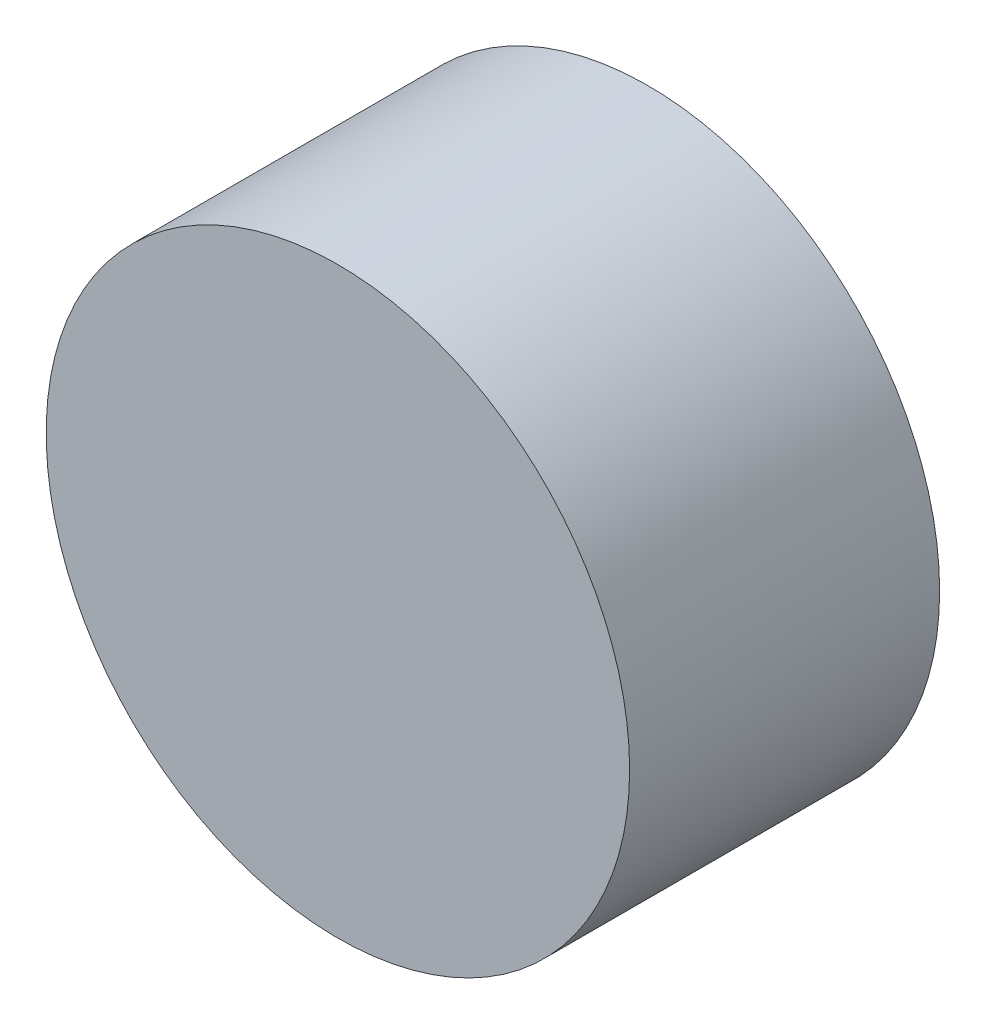
from build123d import *

# Parameters (mm, degrees)
SKETCH1_R           = 9.41
BOSS_EXTRUDE1_DEPTH = 10


with BuildPart() as part:
    # Sketch1 → Boss-Extrude1 (new body)
    with BuildSketch(Plane.XY):
        Circle(SKETCH1_R)
    extrude(amount=BOSS_EXTRUDE1_DEPTH)


solid = part.part
